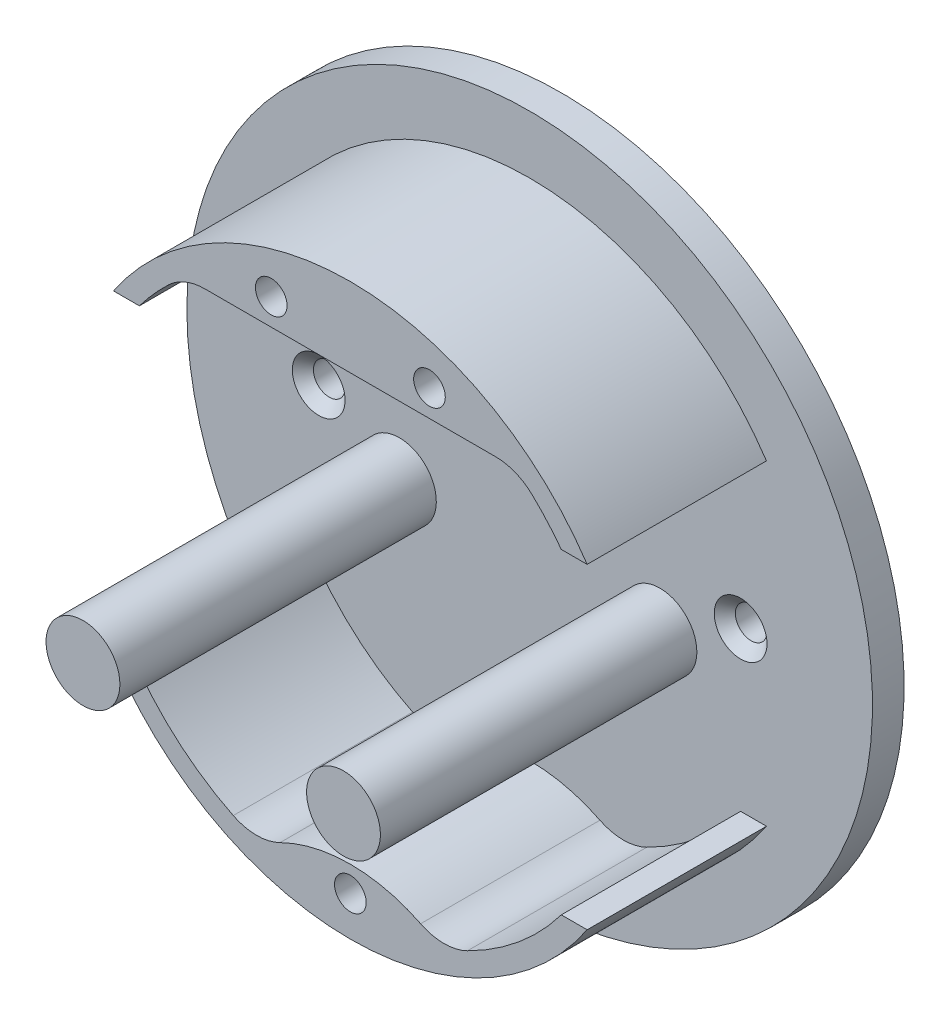
from build123d import *

# Parameters (mm, degrees)
SKETCH3_R               = 27
SKETCH3_R_2             = 25
BOSS_EXTRUDE2_DEPTH     = 20
SKETCH4_W               = 21.394887062
SKETCH4_H               = 30
CUT_EXTRUDE1_DEPTH      = 28
CUT_EXTRUDE1_DEPTH_BACK = 28
SKETCH5_R               = 1.5
BOSS_EXTRUDE3_DEPTH     = 20
FILLET2_R               = 5
SKETCH6_R               = 32.5
BOSS_EXTRUDE4_DEPTH     = 3
SKETCH7_R               = 4
CUT_EXTRUDE2_DEPTH      = 4
SKETCH8_R               = 1.5
CUT_EXTRUDE3_DEPTH      = 4
CHAMFER1_SIZE           = 1
SKETCH9_R               = 3.5
BOSS_EXTRUDE5_DEPTH     = 30


with BuildPart() as part:
    # Sketch3 → Boss-Extrude2 (new body)
    with BuildSketch(Plane.XY):
        Circle(SKETCH3_R)
        Circle(SKETCH3_R_2, mode=Mode.SUBTRACT)
    extrude(amount=BOSS_EXTRUDE2_DEPTH)

    # Sketch4 → Cut-Extrude1 (cut, two sides)
    with BuildSketch(Plane(origin=(0, 0, 0), x_dir=(0, 0, -1), z_dir=(1, 0, 0))) as cut_extrude1_sk:
        with Locations((-13.697443531, 0)):
            Rectangle(SKETCH4_W, SKETCH4_H)
    extrude(amount=CUT_EXTRUDE1_DEPTH, mode=Mode.SUBTRACT)
    extrude(cut_extrude1_sk.sketch, amount=-CUT_EXTRUDE1_DEPTH_BACK, mode=Mode.SUBTRACT)

    # Sketch5 → Boss-Extrude3 (add)
    with BuildSketch(Plane.XY):
        with BuildLine():
            Line((-15.644487847, 19.5), (15.644487847, 19.5))
            ThreePointArc((15.644487847, 19.5), (0, 26.287924728), (-15.644487847, 19.5))
        make_face()
        with Locations((-7.5, 22.007101127)):
            Circle(SKETCH5_R, mode=Mode.SUBTRACT)
        with Locations((7.5, 22.007101127)):
            Circle(SKETCH5_R, mode=Mode.SUBTRACT)
        with BuildLine():
            ThreePointArc((8.529361055, -23.5), (0, -20.838962679), (-8.529361055, -23.5))
            ThreePointArc((-8.529361055, -23.5), (0, -26.208671307), (8.529361055, -23.5))
        make_face()
        with Locations((0, -23.25)):
            Circle(SKETCH5_R, mode=Mode.SUBTRACT)
    extrude(amount=BOSS_EXTRUDE3_DEPTH)

    # Fillet2
    fillet2_edges = [part.edges().sort_by_distance(p)[0] for p in [
        (15.644487847, 19.5, 10),
        (-15.644487847, 19.5, 10),
        (-8.529361055, -23.5, 10),
        (8.529361055, -23.5, 10),
    ]]
    fillet(fillet2_edges, radius=FILLET2_R)

    # Sketch6 → Boss-Extrude4 (add)
    with BuildSketch(Plane(origin=(0, 0, 0), x_dir=(-1, 0, 0), z_dir=(0, 0, -1))):
        Circle(SKETCH6_R)
    extrude(amount=-BOSS_EXTRUDE4_DEPTH)

    # Sketch7 → Cut-Extrude2 (cut, through all)
    with BuildSketch(Plane.XY.offset(3)):
        with Locations((0, 15)):
            Circle(SKETCH7_R)
    extrude(amount=-CUT_EXTRUDE2_DEPTH, mode=Mode.SUBTRACT)

    # Sketch8 → Cut-Extrude3 (cut, through all)
    with BuildSketch(Plane.XY.offset(3)):
        with Locations((-20, 0)):
            Circle(SKETCH8_R)
        with Locations((20, 0)):
            Circle(SKETCH8_R)
    extrude(amount=-CUT_EXTRUDE3_DEPTH, mode=Mode.SUBTRACT)

    # Chamfer1
    chamfer1_edges = [part.edges().sort_by_distance(p)[0] for p in [
        (-21.5, 0, 3),
        (18.5, 0, 3),
    ]]
    chamfer(chamfer1_edges, length=CHAMFER1_SIZE)

    # Sketch9 → Boss-Extrude5 (add)
    with BuildSketch(Plane.XY.offset(3)):
        with Locations((-12.35, -4)):
            Circle(SKETCH9_R)
        with Locations((12.35, -4)):
            Circle(SKETCH9_R)
    extrude(amount=BOSS_EXTRUDE5_DEPTH)


solid = part.part
